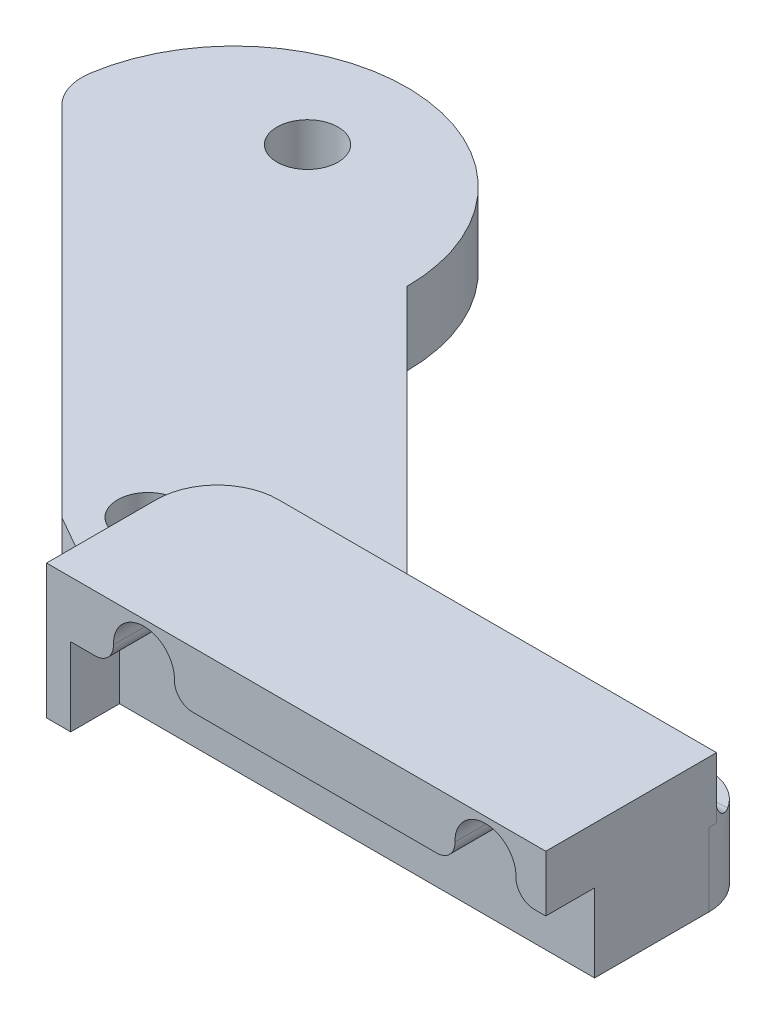
from build123d import *

# Parameters (mm, degrees)
SKETCH1_R                       = 3.175
BOSS_EXTRUDE1_DEPTH             = 3.81
FILLET1_R                       = 5.08
SKETCH3_R                       = 3.175
CUT_EXTRUDE2_DEPTH              = 8.62
BOSS_EXTRUDE2_DEPTH             = 6.35
SKETCH6_R                       = 2.286
CUT_EXTRUDE3_DEPTH              = 6.35
BOSS_EXTRUDE3_DEPTH             = 5.08
FILLET2_R                       = 1.905
FILLET3_R                       = 1.905
BOSS_EXTRUDE4_REACH             = 8.35
BOSS_EXTRUDE4_DIRECTION_2_REACH = 9.62


with BuildPart() as part:
    # Sketch1 → Boss-Extrude1 (new body, symmetric)
    with BuildSketch(Plane(origin=(0, 0, 0), x_dir=(1, 0, 0), z_dir=(0, 1, 0))):
        with BuildLine():
            Line((-43.270256121, 34.29), (-4.490128061, -4.490128061))
            Line((-4.490128061, -4.490128061), (6.35, -10.668))
            Line((6.35, -10.668), (57.15, -10.668))
            Line((57.15, -10.668), (57.15, 6.35))
            Line((57.15, 6.35), (20.590768363, 6.35))
            Line((20.590768363, 6.35), (-7.349231637, 34.29))
            ThreePointArc((-7.349231637, 34.29), (-25.309743879, 52.250512242), (-43.270256121, 34.29))
        make_face()
        Circle(SKETCH1_R, mode=Mode.SUBTRACT)
    extrude(amount=BOSS_EXTRUDE1_DEPTH, both=True)

    # Fillet1
    fillet1_edges = [part.edges().sort_by_distance(p)[0] for p in [
        (-43.270256121, 0, -34.29),
        (20.590768363, 0, -6.35),
        (57.15, 0, -6.35),
        (6.35, 0, 10.668),
    ]]
    fillet(fillet1_edges, radius=FILLET1_R)

    # Sketch3 → Cut-Extrude2 (cut, through all)
    with BuildSketch(Plane(origin=(0, 3.81, 0), x_dir=(1, 0, 0), z_dir=(0, 1, 0))):
        with Locations((-25.309743879, 41.91)):
            Circle(SKETCH3_R)
    extrude(amount=-CUT_EXTRUDE2_DEPTH, mode=Mode.SUBTRACT)

    # Sketch4 → Boss-Extrude2 (add)
    with BuildSketch(Plane(origin=(0, 3.81, 0), x_dir=(1, 0, 0), z_dir=(0, 1, 0))):
        with BuildLine():
            Line((57.15, -10.668), (7.695948183, -10.668))
            ThreePointArc((7.695948183, -10.668), (6.394891779, -10.498565368), (5.180624356, -10.001563871))
            Line((5.180624356, -10.001563871), (5.180624356, -4.318))
            ThreePointArc((5.180624356, -4.318), (7.040496295, 0.172128061), (11.530624356, 2.032))
            Line((11.530624356, 2.032), (57.15, 2.032))
            Line((57.15, 2.032), (57.15, -10.668))
        make_face()
    extrude(amount=BOSS_EXTRUDE2_DEPTH)

    # Sketch6 → Cut-Extrude3 (cut)
    with BuildSketch(Plane.XY.offset(10.668)):
        with Locations((15.315948183, 6.35)):
            Circle(SKETCH6_R)
        with Locations((50.875948183, 6.35)):
            Circle(SKETCH6_R)
    extrude(amount=-CUT_EXTRUDE3_DEPTH, mode=Mode.SUBTRACT)

    # Sketch7 → Boss-Extrude3 (add)
    with BuildSketch(Plane.XY.offset(10.668)):
        with BuildLine():
            Line((57.15, 10.16), (7.695948183, 10.16))
            Line((7.695948183, 10.16), (7.695948183, 4.318))
            Line((7.695948183, 4.318), (12.876357848, 4.318))
            ThreePointArc((12.876357848, 4.318), (14.235456237, 9.335491945), (18.490948183, 6.35))
            ThreePointArc((18.490948183, 6.35), (18.301440128, 5.269508055), (17.755538517, 4.318))
            Line((17.755538517, 4.318), (48.436357848, 4.318))
            ThreePointArc((48.436357848, 4.318), (49.795456237, 9.335491945), (54.050948183, 6.35))
            ThreePointArc((54.050948183, 6.35), (53.861440128, 5.269508055), (53.315538517, 4.318))
            Line((53.315538517, 4.318), (57.15, 4.318))
            Line((57.15, 4.318), (57.15, 10.16))
        make_face()
    extrude(amount=BOSS_EXTRUDE3_DEPTH)

    # Fillet2
    fillet2_edges = [part.edges().sort_by_distance(p)[0] for p in [
        (53.315538517, 4.318, 13.208),
        (12.876357848, 4.318, 13.208),
        (17.755538517, 4.318, 13.208),
        (48.436357848, 4.318, 13.208),
    ]]
    fillet(fillet2_edges, radius=FILLET2_R)

    # Fillet3
    fillet3_edges = [part.edges().sort_by_distance(p)[0] for p in [
        (34.31157461, 3.81, -2.032),
        (7.040496295, 3.81, -0.172128061),
        (5.180624356, 3.81, 7.159781936),
    ]]
    fillet(fillet3_edges, radius=FILLET3_R)

    # Boss-Extrude4: up to this face of the body (flat: up to its plane)
    boss_extrude4_end = Plane(part.part.faces().sort_by_distance((31.766522001, 10.16, 6.837548853))[0])
    # Sketch8 → Boss-Extrude4 (add, up to the picked face)
    with BuildSketch(Plane(origin=(0, 3.81, 0), x_dir=(1, 0, 0), z_dir=(0, 1, 0)), mode=Mode.PRIVATE) as boss_extrude4_sk1:
        with BuildLine():
            Line((5.180624356, -15.748), (7.695948183, -15.748))
            Line((7.695948183, -15.748), (7.695948183, -10.668))
            ThreePointArc((7.695948183, -10.668), (6.394891779, -10.498565368), (5.180624356, -10.001563871))
            Line((5.180624356, -10.001563871), (5.180624356, -15.748))
        make_face()
    boss_extrude4_tool1 = split(extrude(boss_extrude4_sk1.sketch, amount=BOSS_EXTRUDE4_REACH, mode=Mode.PRIVATE), bisect_by=boss_extrude4_end, keep=Keep.BOTH, mode=Mode.PRIVATE)
    add(boss_extrude4_tool1.solids().sort_by_distance((6.412294, 3.81, 13.096367))[0])

    # Boss-Extrude4 direction 2: up to this face of the body (flat: up to its plane)
    boss_extrude4_direction_2_end = Plane(part.part.faces().sort_by_distance((1.392944323, -3.81, -15.281162376))[0])
    # Sketch8 → Boss-Extrude4 direction 2 (add, up to the picked face)
    with BuildSketch(Plane(origin=(0, 3.81, 0), x_dir=(1, 0, 0), z_dir=(0, 1, 0)), mode=Mode.PRIVATE) as boss_extrude4_direction_2_sk1:
        with BuildLine():
            Line((5.180624356, -15.748), (7.695948183, -15.748))
            Line((7.695948183, -15.748), (7.695948183, -10.668))
            ThreePointArc((7.695948183, -10.668), (6.394891779, -10.498565368), (5.180624356, -10.001563871))
            Line((5.180624356, -10.001563871), (5.180624356, -15.748))
        make_face()
    boss_extrude4_direction_2_tool1 = split(extrude(boss_extrude4_direction_2_sk1.sketch, amount=-BOSS_EXTRUDE4_DIRECTION_2_REACH, mode=Mode.PRIVATE), bisect_by=boss_extrude4_direction_2_end, keep=Keep.BOTH, mode=Mode.PRIVATE)
    add(boss_extrude4_direction_2_tool1.solids().sort_by_distance((6.412294, 3.81, 13.096367))[0])


solid = part.part
